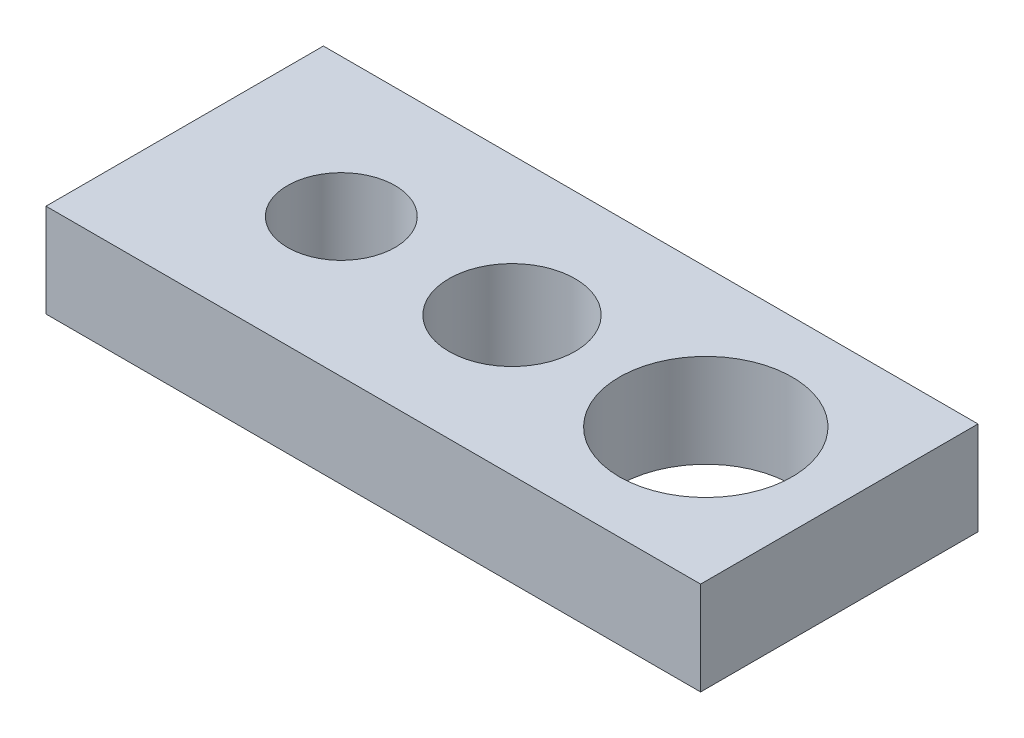
from build123d import *

# Parameters (mm, degrees)
SKETCH1_W           = 14.011388394
SKETCH1_H           = 5.937625438
SKETCH1_R           = 1.15
SKETCH1_R_2         = 1.35
SKETCH1_R_3         = 1.85
BOSS_EXTRUDE1_DEPTH = 2


with BuildPart() as part:
    # Sketch1 → Boss-Extrude1 (new body)
    with BuildSketch(Plane(origin=(0, 0, 0), x_dir=(1, 0, 0), z_dir=(0, 1, 0))):
        Rectangle(SKETCH1_W, SKETCH1_H)
        with Locations((-3.653842684, 0)):
            Circle(SKETCH1_R, mode=Mode.SUBTRACT)
        Circle(SKETCH1_R_2, mode=Mode.SUBTRACT)
        with Locations((4.147880665, 0)):
            Circle(SKETCH1_R_3, mode=Mode.SUBTRACT)
    extrude(amount=BOSS_EXTRUDE1_DEPTH)


solid = part.part
